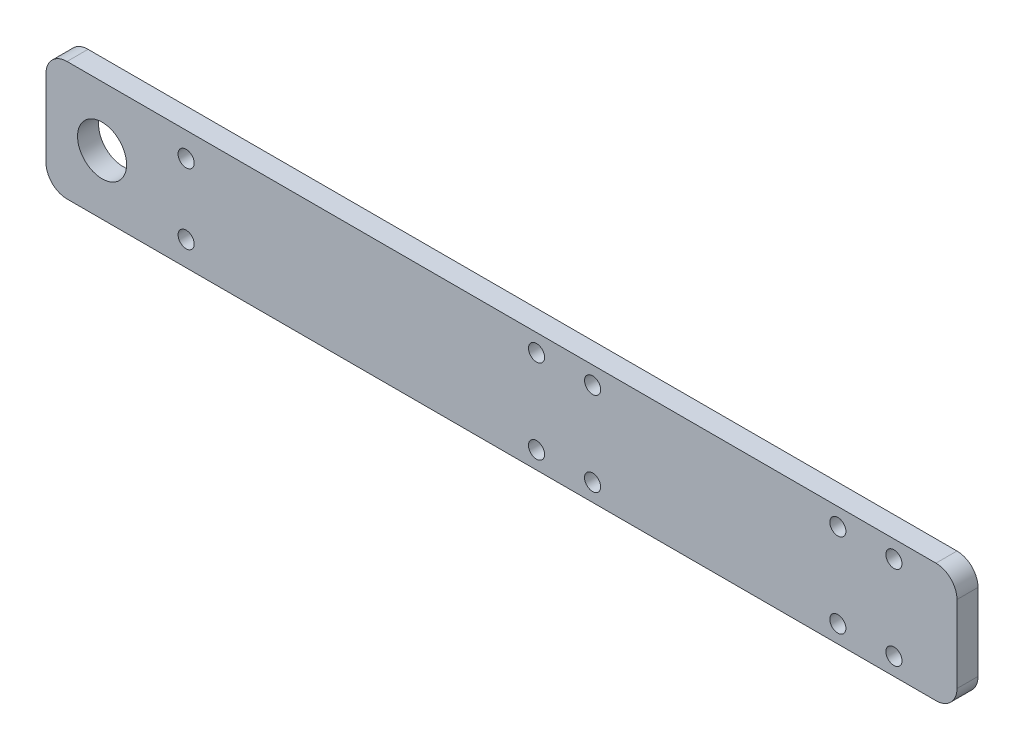
from build123d import *

# Parameters (mm, degrees)
SKETCH_1_W      = 130
SKETCH_1_H      = 17
SKETCH_1_R      = 3.5
SKETCH_1_R_2    = 1.15
EXTRUDE_1_DEPTH = 3
FILLET_1_R      = 3


with BuildPart() as part:
    # 草图1 → 凸台-拉伸1 (new body)
    with BuildSketch(Plane.XY):
        Rectangle(SKETCH_1_W, SKETCH_1_H)
        with Locations((-57, 0)):
            Circle(SKETCH_1_R, mode=Mode.SUBTRACT)
        with Locations((-45, 5)):
            Circle(SKETCH_1_R_2, mode=Mode.SUBTRACT)
        with Locations((-45, -5)):
            Circle(SKETCH_1_R_2, mode=Mode.SUBTRACT)
        with Locations((5, 6)):
            Circle(SKETCH_1_R_2, mode=Mode.SUBTRACT)
        with Locations((13, 6)):
            Circle(SKETCH_1_R_2, mode=Mode.SUBTRACT)
        with Locations((5, -6)):
            Circle(SKETCH_1_R_2, mode=Mode.SUBTRACT)
        with Locations((13, -6)):
            Circle(SKETCH_1_R_2, mode=Mode.SUBTRACT)
        with Locations((48, 6)):
            Circle(SKETCH_1_R_2, mode=Mode.SUBTRACT)
        with Locations((56, 6)):
            Circle(SKETCH_1_R_2, mode=Mode.SUBTRACT)
        with Locations((56, -6)):
            Circle(SKETCH_1_R_2, mode=Mode.SUBTRACT)
        with Locations((48, -6)):
            Circle(SKETCH_1_R_2, mode=Mode.SUBTRACT)
    extrude(amount=EXTRUDE_1_DEPTH)

    # 圆角1
    fillet_1_edges = [part.edges().sort_by_distance(p)[0] for p in [
        (65, -8.5, 1.5),
        (-65, -8.5, 1.5),
        (-65, 8.5, 1.5),
        (65, 8.5, 1.5),
    ]]
    fillet(fillet_1_edges, radius=FILLET_1_R)


solid = part.part
